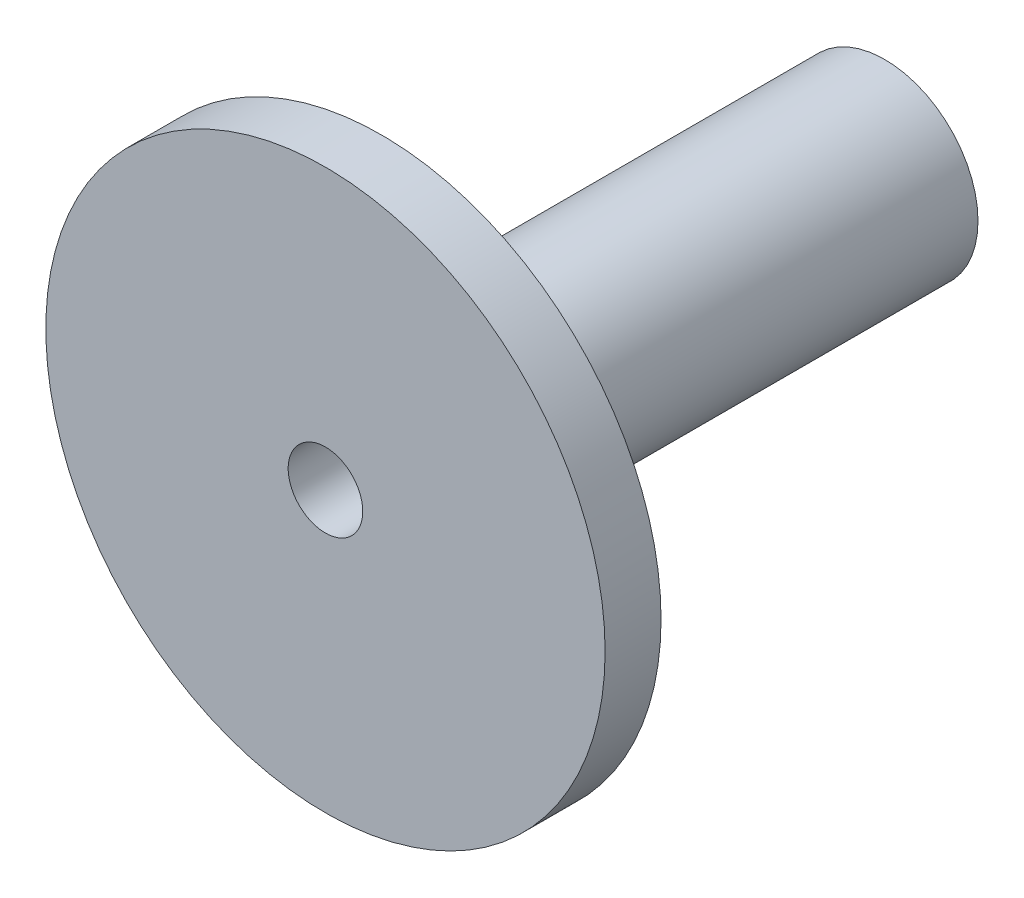
from build123d import *

# Parameters (mm, degrees)
SKETCH1_R           = 5
BOSS_EXTRUDE1_DEPTH = 30
SKETCH2_R           = 2
CUT_EXTRUDE1_DEPTH  = 31
SKETCH4_R           = 15
SKETCH4_R_2         = 5
BOSS_EXTRUDE3_DEPTH = 3


with BuildPart() as part:
    # Sketch1 → Boss-Extrude1 (new body)
    with BuildSketch(Plane.XY):
        Circle(SKETCH1_R)
    extrude(amount=BOSS_EXTRUDE1_DEPTH)

    # Sketch2 → Cut-Extrude1 (cut, through all)
    with BuildSketch(Plane.XY.offset(30)):
        Circle(SKETCH2_R)
    extrude(amount=-CUT_EXTRUDE1_DEPTH, mode=Mode.SUBTRACT)

    # Sketch4 → Boss-Extrude3 (add)
    with BuildSketch(Plane.XY.offset(30)):
        Circle(SKETCH4_R)
        Circle(SKETCH4_R_2, mode=Mode.SUBTRACT)
    extrude(amount=-BOSS_EXTRUDE3_DEPTH)


solid = part.part
